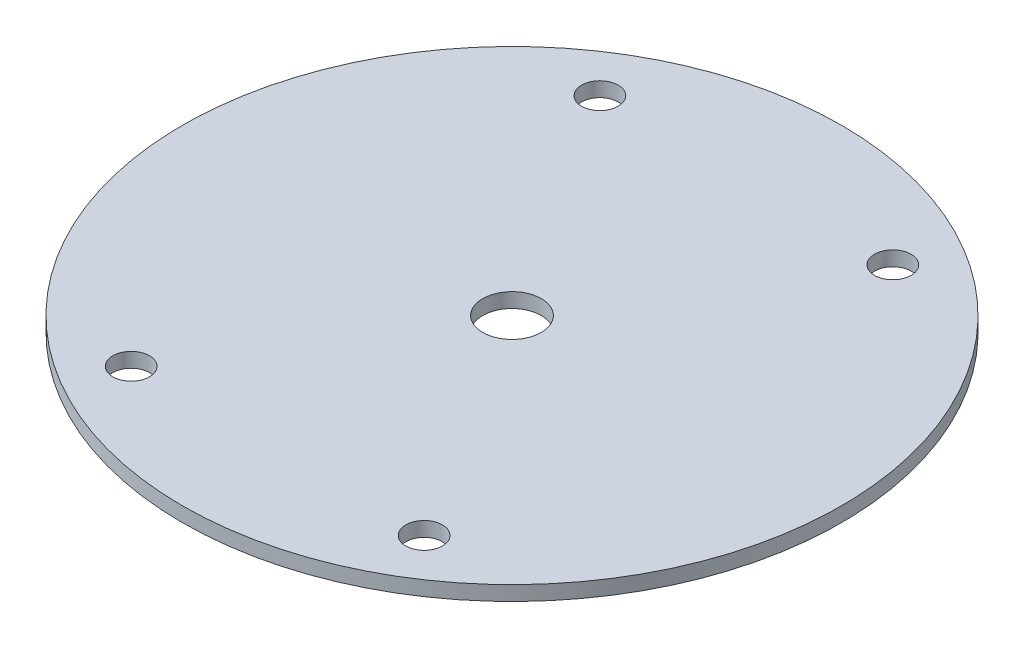
from build123d import *

# Parameters (mm, degrees)
SKETCH1_R           = 45
SKETCH1_R_2         = 2.5
SKETCH1_R_3         = 4
BOSS_EXTRUDE1_DEPTH = 2


with BuildPart() as part:
    # Sketch1 → Boss-Extrude1 (new body)
    with BuildSketch(Plane(origin=(0, 0, 0), x_dir=(1, 0, 0), z_dir=(0, 1, 0))):
        Circle(SKETCH1_R)
        with Locations((-20, 32)):
            Circle(SKETCH1_R_2, mode=Mode.SUBTRACT)
        with Locations((20, 32)):
            Circle(SKETCH1_R_2, mode=Mode.SUBTRACT)
        with Locations((20, -32)):
            Circle(SKETCH1_R_2, mode=Mode.SUBTRACT)
        with Locations((-20, -32)):
            Circle(SKETCH1_R_2, mode=Mode.SUBTRACT)
        Circle(SKETCH1_R_3, mode=Mode.SUBTRACT)
    extrude(amount=BOSS_EXTRUDE1_DEPTH)


solid = part.part
